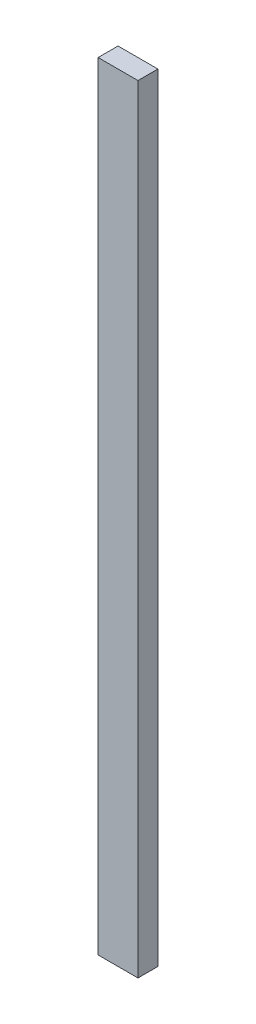
from build123d import *

# Parameters (mm, degrees)
SKETCH_1_W      = 40
SKETCH_1_H      = 20
EXTRUDE_1_DEPTH = 780


with BuildPart() as part:
    # Эскиз1 → Бобышка-Вытянуть1 (new body)
    with BuildSketch(Plane(origin=(0, 0, 0), x_dir=(1, 0, 0), z_dir=(0, 1, 0))):
        with Locations((20, 10)):
            Rectangle(SKETCH_1_W, SKETCH_1_H)
    extrude(amount=EXTRUDE_1_DEPTH)


solid = part.part
